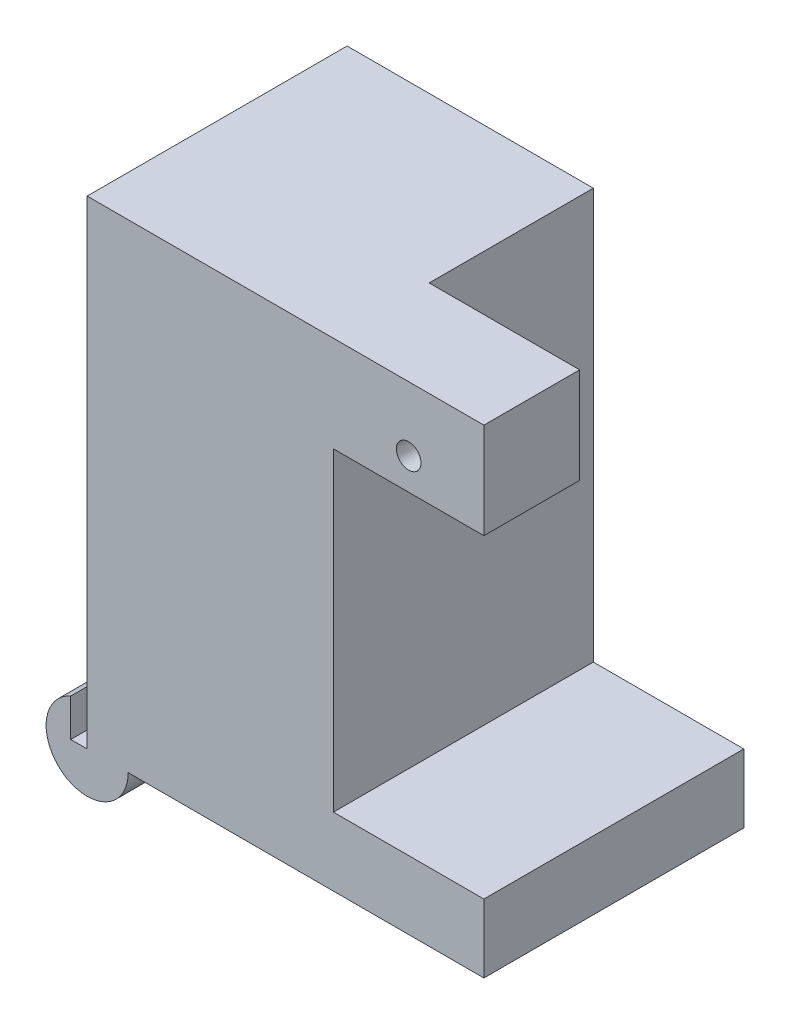
from build123d import *

# Parameters (mm, degrees)
SKETCH1_W           = 18
SKETCH1_H           = 19
BOSS_EXTRUDE1_DEPTH = 35
SKETCH2_W           = 19
SKETCH2_H           = 5
SKETCH2_H_2         = 7
BOSS_EXTRUDE2_DEPTH = 11
SKETCH3_W           = 12
SKETCH3_H           = 7
CUT_EXTRUDE1_DEPTH  = 11
SKETCH7_W           = 3
SKETCH7_H           = 19
SKETCH9_W           = 39
SKETCH9_H           = 6
CUT_EXTRUDE3_DEPTH  = 4
SKETCH10_W          = 6
SKETCH10_H          = 35
CUT_EXTRUDE4_DEPTH  = 4
SKETCH11_W          = 1.2
SKETCH11_H          = 19
CUT_EXTRUDE5_DEPTH  = 35
SKETCH12_R          = 1.4
CUT_EXTRUDE6_DEPTH  = 5
SKETCH13_R          = 0.9
CUT_EXTRUDE7_DEPTH  = 20


with BuildPart() as part:
    # Sketch1 → Boss-Extrude1 (new body)
    with BuildSketch(Plane(origin=(0, 0, 0), x_dir=(1, 0, 0), z_dir=(0, 1, 0))):
        with Locations((-1.30615381, -1.556170273)):
            Rectangle(SKETCH1_W, SKETCH1_H)
    extrude(amount=BOSS_EXTRUDE1_DEPTH)

    # Sketch2 → Boss-Extrude2 (add)
    with BuildSketch(Plane(origin=(7.69384619, 0, 0), x_dir=(0, 0, -1), z_dir=(1, 0, 0))):
        with Locations((-1.556170273, 2.5)):
            Rectangle(SKETCH2_W, SKETCH2_H)
        with Locations((-1.556170273, 31.5)):
            Rectangle(SKETCH2_W, SKETCH2_H_2)
    extrude(amount=BOSS_EXTRUDE2_DEPTH)

    # Sketch3 → Cut-Extrude1 (cut)
    with BuildSketch(Plane(origin=(18.69384619, 0, 0), x_dir=(0, 0, -1), z_dir=(1, 0, 0))):
        with Locations((1.943829727, 31.5)):
            Rectangle(SKETCH3_W, SKETCH3_H)
    extrude(amount=-CUT_EXTRUDE1_DEPTH, mode=Mode.SUBTRACT)

    # Sketch7 → Revolve2 (revolve)
    with BuildSketch(Plane.XZ):
        with Locations((-8.80615381, 1.556170273)):
            Rectangle(SKETCH7_W, SKETCH7_H)
    revolve(axis=Axis((-10.30615381, 0, -7.943829727), (0, 0, 1)))

    # Sketch9 → Cut-Extrude3 (cut, through all)
    with BuildSketch(Plane.XZ):
        with Locations((-0.80615381, -4.943829727)):
            Rectangle(SKETCH9_W, SKETCH9_H)
    extrude(amount=CUT_EXTRUDE3_DEPTH, mode=Mode.SUBTRACT)

    # Sketch10 → Cut-Extrude4 (cut, through all)
    with BuildSketch(Plane.ZY.offset(10.30615381)):
        with Locations((-4.943829727, 17.5)):
            Rectangle(SKETCH10_W, SKETCH10_H)
    extrude(amount=CUT_EXTRUDE4_DEPTH, mode=Mode.SUBTRACT)

    # Sketch11 → Cut-Extrude5 (cut)
    with BuildSketch(Plane(origin=(0, 35, 0), x_dir=(1, 0, 0), z_dir=(0, 1, 0))):
        with Locations((-10.90615381, -1.556170273)):
            Rectangle(SKETCH11_W, SKETCH11_H)
    extrude(amount=-CUT_EXTRUDE5_DEPTH, mode=Mode.SUBTRACT)

    # Sketch12 → Cut-Extrude6 (cut)
    with BuildSketch(Plane.ZY.offset(10.30615381)):
        with Locations((-3.943829727, 4)):
            Circle(SKETCH12_R)
    extrude(amount=-CUT_EXTRUDE6_DEPTH, mode=Mode.SUBTRACT)

    # Sketch13 → Cut-Extrude7 (cut, through all)
    with BuildSketch(Plane.XY.offset(11.056170273)):
        with Locations((13.19384619, 30.3)):
            Circle(SKETCH13_R)
    extrude(amount=-CUT_EXTRUDE7_DEPTH, mode=Mode.SUBTRACT)


solid = part.part
